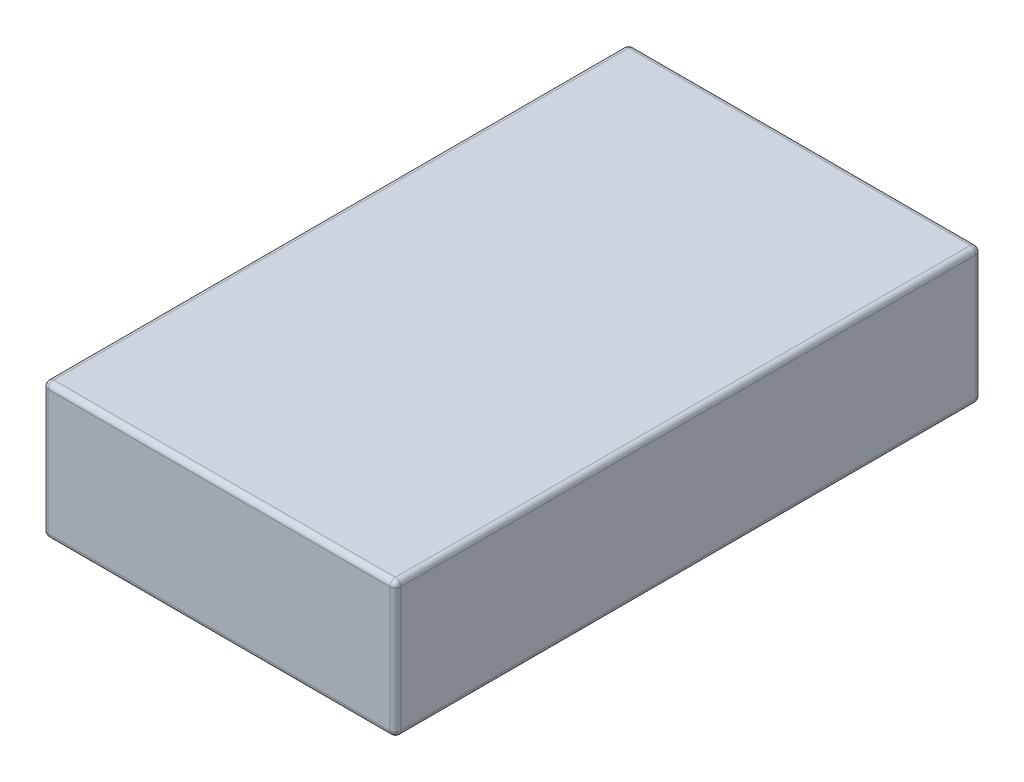
from build123d import *

# Parameters (mm, degrees)
SKETCH1_W           = 65
SKETCH1_H           = 108
BOSS_EXTRUDE1_DEPTH = 25
FILLET1_R           = 1


with BuildPart() as part:
    # Sketch1 → Boss-Extrude1 (new body)
    with BuildSketch(Plane(origin=(0, 0, 0), x_dir=(1, 0, 0), z_dir=(0, 1, 0))):
        Rectangle(SKETCH1_W, SKETCH1_H)
    extrude(amount=BOSS_EXTRUDE1_DEPTH)

    # Fillet1
    fillet1_edges = [part.edges().sort_by_distance(p)[0] for p in [
        (-32.5, 25, 0),
        (0, 25, 54),
        (32.5, 25, 0),
        (0, 0, 54),
        (-32.5, 0, 0),
        (0, 0, -54),
        (32.5, 0, 0),
        (32.5, 12.5, 54),
        (-32.5, 12.5, 54),
        (-32.5, 12.5, -54),
        (32.5, 12.5, -54),
        (0, 25, -54),
    ]]
    fillet(fillet1_edges, radius=FILLET1_R)


solid = part.part
